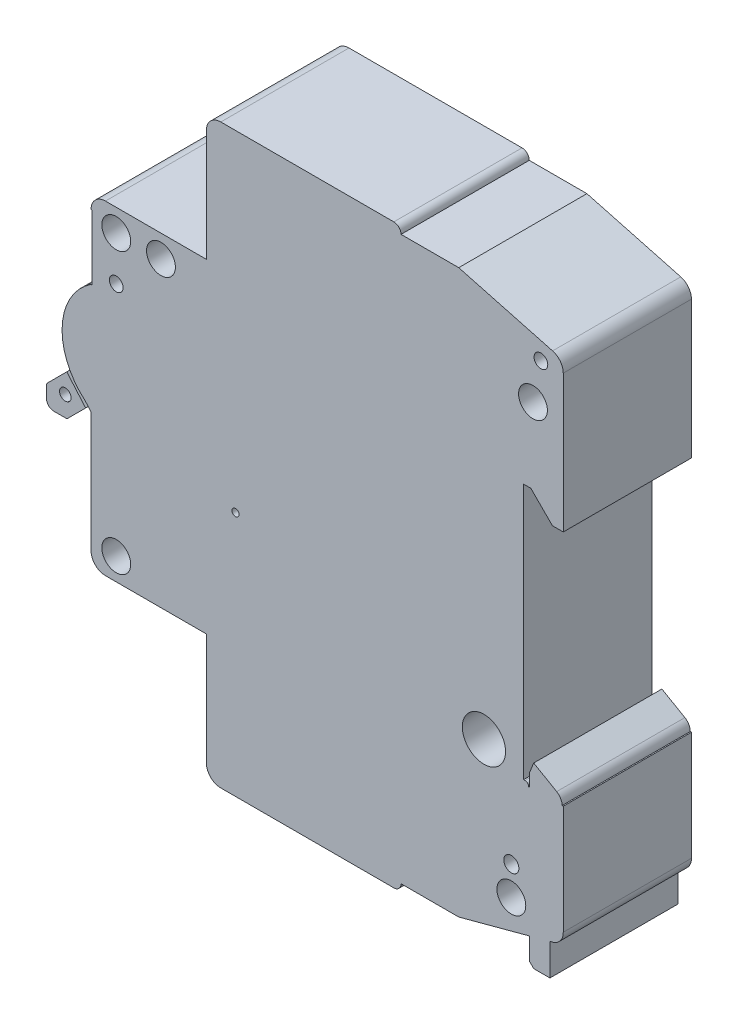
from build123d import *

# Parameters (mm, degrees)
SKETCH1_R           = 0.95
SKETCH1_R_2         = 2
SKETCH1_R_3         = 3
SKETCH1_R_4         = 1.047925013
SKETCH1_R_5         = 0.495
SKETCH1_R_6         = 0.65
BOSS_EXTRUDE1_DEPTH = 17.78
CUT_EXTRUDE1_DEPTH  = 14.78
BOSS_EXTRUDE2_DEPTH = 3
SKETCH4_W           = 10.78
SKETCH4_H           = 1.889736425
CUT_EXTRUDE2_DEPTH  = 2.5
SKETCH5_W           = 10.78
SKETCH5_H           = 1.889736425
BOSS_EXTRUDE3_DEPTH = 3
SKETCH6_R           = 0.8
BOSS_EXTRUDE4_DEPTH = 17.78


with BuildPart() as part:
    # Sketch1 → Boss-Extrude1 (new body)
    with BuildSketch(Plane.XY):
        with BuildLine():
            Line((35.5, 14.5), (34, 14.5))
            Line((34, 14.5), (31, 17.5))
            Line((31, 17.5), (30, 17.5))
            Line((30, 17.5), (30, -18))
            Line((30, -18), (30.2, -18))
            ThreePointArc((30.2, -18), (30.553553391, -18.146446609), (30.7, -18.5))
            Line((30.7, -18.5), (30.8, -18.5))
            Line((30.8, -18.5), (30.8, -16.8))
            Line((30.8, -16.8), (31.4, -15.3))
            Line((31.4, -15.3), (34.5875, -17.140303983))
            ThreePointArc((34.5875, -17.140303983), (35.136538106, -17.689342089), (35.3375, -18.439342089))
            Line((35.3375, -18.439342089), (35.5, -18.439342089))
            Line((35.5, -18.439342089), (35.5, -33.580082734))
            ThreePointArc((35.5, -33.580082734), (34.978350458, -34.92710906), (33.685520077, -35.57145972))
            Line((33.685520077, -35.57145972), (33.65, -35.610442716))
            Line((33.65, -35.610442716), (33.65, -40))
            Line((33.65, -40), (31.4, -40))
            Line((31.4, -40), (30.8, -39.4))
            Line((30.8, -39.4), (30.8, -36.374097914))
            Line((30.8, -36.374097914), (21, -39))
            Line((21, -39), (13, -39))
            ThreePointArc((13, -39), (12.707106781, -39.707106781), (12, -40))
            Line((12, -40), (-12, -40))
            ThreePointArc((-12, -40), (-13.414213562, -39.414213562), (-14, -38))
            Line((-14, -38), (-14, -22.5))
            Line((-14, -22.5), (-28, -22.5))
            ThreePointArc((-28, -22.5), (-29.414213562, -21.914213562), (-30, -20.5))
            Line((-30, -20.5), (-30, -3.828427125))
            Line((-30, -3.828427125), (-30.86027165, -2.830608771))
            Line((-30.86027165, -2.830608771), (-32.619050385, -0.790623261))
            ThreePointArc((-32.619050385, -0.790623261), (-33.80184622, 5.878164829), (-30, 11.483314774))
            Line((-30, 11.483314774), (-29.873, 11.483314774))
            Line((-29.873, 11.483314774), (-29.873, 20.5))
            Line((-29.873, 20.5), (-30, 20.5))
            ThreePointArc((-30, 20.5), (-29.414213562, 21.914213562), (-28, 22.5))
            Line((-28, 22.5), (-14, 22.5))
            Line((-14, 22.5), (-14, 38))
            ThreePointArc((-14, 38), (-13.414213562, 39.414213562), (-12, 40))
            Line((-12, 40), (12, 40))
            ThreePointArc((12, 40), (12.707106781, 39.707106781), (13, 39))
            Line((13, 39), (21, 39))
            Line((21, 39), (34.017568937, 35.512452349))
            ThreePointArc((34.017568937, 35.512452349), (35.086684889, 34.798133425), (35.5, 33.580582168))
            Line((35.5, 33.580582168), (35.5, 14.5))
        make_face()
        with Locations((32.4, 33.5)):
            Circle(SKETCH1_R, mode=Mode.SUBTRACT)
        with Locations((31.3, 28)):
            Circle(SKETCH1_R_2, mode=Mode.SUBTRACT)
        with Locations((24.5, -15.9)):
            Circle(SKETCH1_R_3, mode=Mode.SUBTRACT)
        with Locations((28.297263495, -29)):
            Circle(SKETCH1_R_4, mode=Mode.SUBTRACT)
        with Locations((28.297263495, -33)):
            Circle(SKETCH1_R_2, mode=Mode.SUBTRACT)
        with Locations((-26.5, -19.4)):
            Circle(SKETCH1_R_2, mode=Mode.SUBTRACT)
        with Locations((-9.958595339, -5.892279985)):
            Circle(SKETCH1_R_5, mode=Mode.SUBTRACT)
        with Locations((-32.65, 4)):
            Circle(SKETCH1_R_6, mode=Mode.SUBTRACT)
        with Locations((-26.5, 13.3)):
            Circle(SKETCH1_R, mode=Mode.SUBTRACT)
        with Locations((-26.5, 19.4)):
            Circle(SKETCH1_R_2, mode=Mode.SUBTRACT)
        with Locations((-20.3, 19.4)):
            Circle(SKETCH1_R_2, mode=Mode.SUBTRACT)
    extrude(amount=BOSS_EXTRUDE1_DEPTH)

    # Sketch2 → Cut-Extrude1 (cut)
    with BuildSketch(Plane.XY.offset(17.78)):
        with BuildLine():
            Line((-31.427876097, 11.660444431), (-29.178119463, 8.97928888))
            ThreePointArc((-29.178119463, 8.97928888), (-31.5, 4), (-29.178119463, -0.97928888))
            Line((-29.178119463, -0.97928888), (-31.427876097, -3.660444431))
            ThreePointArc((-31.427876097, -3.660444431), (-35, 4), (-31.427876097, 11.660444431))
        make_face()
    extrude(amount=-CUT_EXTRUDE1_DEPTH, mode=Mode.SUBTRACT)

    # Sketch3 → Boss-Extrude2 (add)
    with BuildSketch(Plane.XY.offset(17.78)):
        with BuildLine():
            Line((-29.178119463, -0.97928888), (-30.795044426, -2.906265014))
            ThreePointArc((-30.795044426, -2.906265014), (-34.015488692, 4), (-30.795044426, 10.906265014))
            Line((-30.795044426, 10.906265014), (-29.178119463, 8.97928888))
            ThreePointArc((-29.178119463, 8.97928888), (-31.5, 4), (-29.178119463, -0.97928888))
        make_face()
    extrude(amount=-BOSS_EXTRUDE2_DEPTH)

    # Sketch4 → Cut-Extrude2 (cut)
    with BuildSketch(Plane(origin=(-19.102021317, -16.468856625, 0), x_dir=(0, 0, 1), z_dir=(-0.757378649, -0.652975943, 0))):
        with Locations((8.89, 19.255785792)):
            Rectangle(SKETCH4_W, SKETCH4_H)
    extrude(amount=-CUT_EXTRUDE2_DEPTH, mode=Mode.SUBTRACT)

    # Sketch5 → Boss-Extrude3 (add)
    with BuildSketch(Plane(origin=(-17.208574695, -14.836416768, 0), x_dir=(0, 0, 1), z_dir=(-0.757378649, -0.652975943, 0))):
        with Locations((8.89, 19.255785792)):
            Rectangle(SKETCH5_W, SKETCH5_H)
    extrude(amount=BOSS_EXTRUDE3_DEPTH)

    # Sketch6 → Boss-Extrude4 (add)
    with BuildSketch(Plane.XY):
        with BuildLine():
            Line((-33.363800719, -0.692521635), (-30.744750334, -3.730325499))
            Line((-30.744750334, -3.730325499), (-33.186517311, -6.172092477))
            ThreePointArc((-33.186517311, -6.172092477), (-33.347465178, -6.279953339), (-33.53733329, -6.318531593))
            Line((-33.53733329, -6.318531593), (-35.164834129, -6.327442008))
            ThreePointArc((-35.164834129, -6.327442008), (-35.877415735, -6.034563776), (-36.170293967, -5.32198217))
            Line((-36.170293967, -5.32198217), (-36.161383552, -3.69448133))
            ThreePointArc((-36.161383552, -3.69448133), (-36.122805298, -3.504613219), (-36.014944436, -3.343665352))
            Line((-36.014944436, -3.343665352), (-33.363800719, -0.692521635))
        make_face()
        with Locations((-33.569032824, -3.517375453)):
            Circle(SKETCH6_R, mode=Mode.SUBTRACT)
    extrude(amount=BOSS_EXTRUDE4_DEPTH)


solid = part.part
